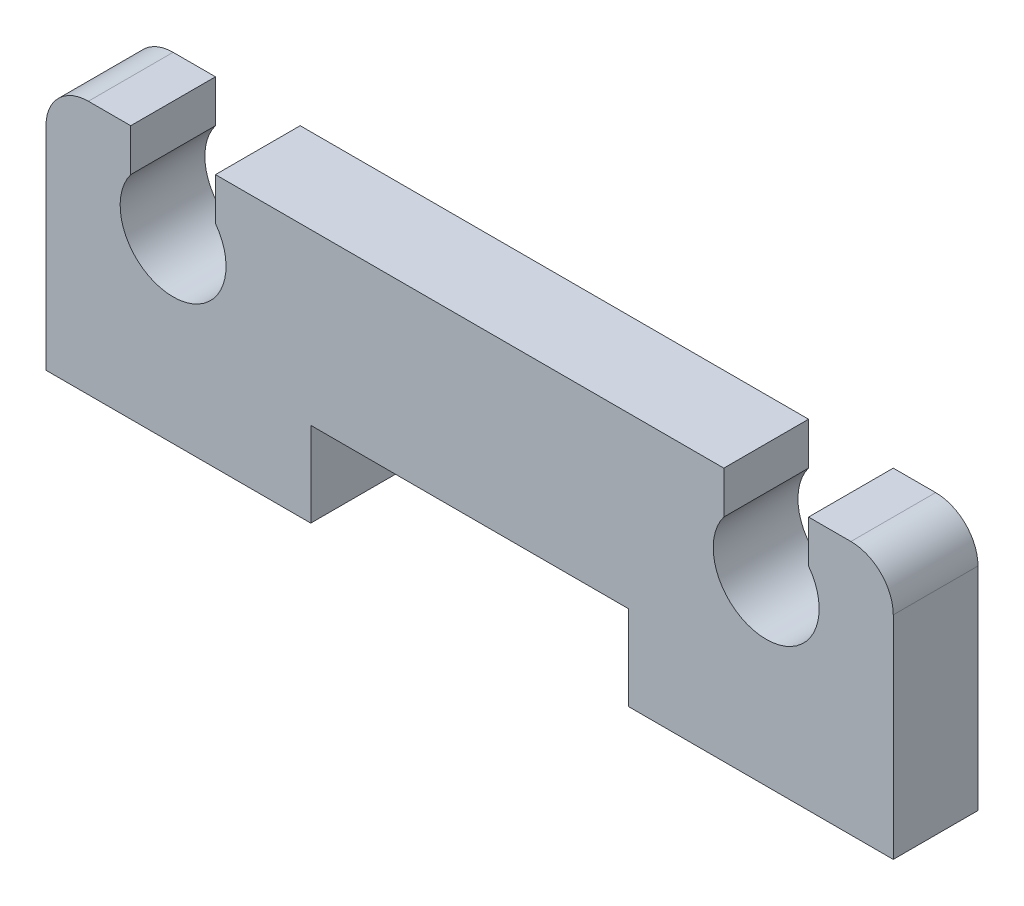
from build123d import *

# Parameters (mm, degrees)
BOSS_EXTRUDE1_DEPTH = 2


with BuildPart() as part:
    # Model → Boss-Extrude1 (new body)
    with BuildSketch(Plane.XY):
        with BuildLine():
            Line((6.25, 2), (13.75, 2))
            Line((13.75, 2), (13.75, 0))
            Line((13.75, 0), (20, 0))
            Line((20, 0), (20, 5))
            ThreePointArc((20, 5), (19.707106781, 5.707106781), (19, 6))
            Line((19, 6), (18, 6))
            Line((18, 6), (18, 5))
            ThreePointArc((18, 5), (17, 3), (16, 5))
            Line((16, 5), (16, 6))
            Line((16, 6), (4, 6))
            Line((4, 6), (4, 5))
            ThreePointArc((4, 5), (3, 3), (2, 5))
            Line((2, 5), (2, 6))
            Line((2, 6), (1, 6))
            ThreePointArc((1, 6), (0.292893219, 5.707106781), (0, 5))
            Line((0, 5), (0, 0))
            Line((0, 0), (6.25, 0))
            Line((6.25, 0), (6.25, 2))
        make_face()
    extrude(amount=BOSS_EXTRUDE1_DEPTH)


solid = part.part
